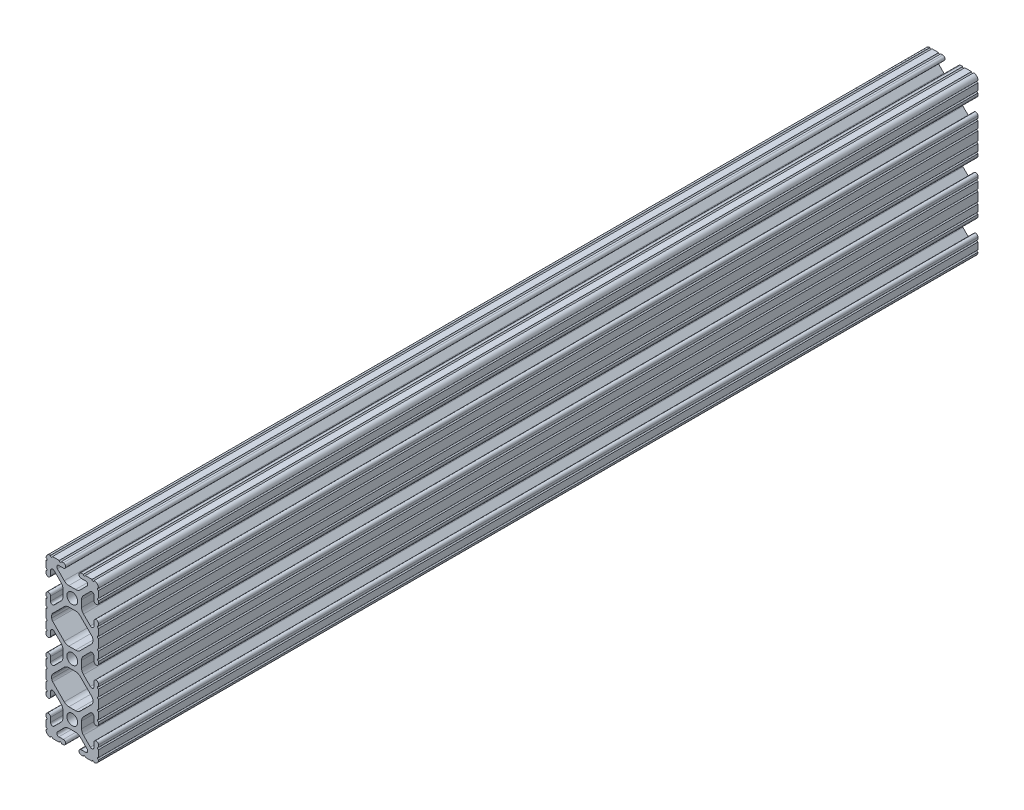
from build123d import *

# Parameters (mm, degrees)
SKETCH1_R           = 2.6035
BOSS_EXTRUDE1_DEPTH = 212.725


with BuildPart() as part:
    # Sketch1 → Boss-Extrude1 (new body, symmetric)
    with BuildSketch(Plane.XY):
        with BuildLine():
            Line((-12.7, 34.9504), (-12.7, 31.7246))
            ThreePointArc((-12.7, 31.7246), (-12.192, 31.2166), (-12.7, 30.7086))
            Line((-12.7, 30.7086), (-12.7, 29.702307889))
            ThreePointArc((-12.7, 29.702307889), (-11.5951, 28.597407889), (-10.4902, 29.702307889))
            Line((-10.4902, 29.702307889), (-10.4902, 31.874794456))
            ThreePointArc((-10.4902, 31.874794456), (-9.863006367, 32.813456061), (-8.75577951, 32.593214945))
            Line((-8.75577951, 32.593214945), (-5.43843597, 29.275871405))
            ThreePointArc((-5.43843597, 29.275871405), (-4.750182484, 28.245827272), (-4.5085, 27.030807374))
            Line((-4.5085, 27.030807374), (-4.5085, 23.769192626))
            ThreePointArc((-4.5085, 23.769192626), (-4.750182484, 22.554172728), (-5.43843597, 21.524128595))
            Line((-5.43843597, 21.524128595), (-8.75577951, 18.206785055))
            ThreePointArc((-8.75577951, 18.206785055), (-9.863006367, 17.986543939), (-10.4902, 18.925205544))
            Line((-10.4902, 18.925205544), (-10.4902, 21.097692111))
            ThreePointArc((-10.4902, 21.097692111), (-11.5951, 22.202592111), (-12.7, 21.097692111))
            Line((-12.7, 21.097692111), (-12.7, 20.0914))
            ThreePointArc((-12.7, 20.0914), (-12.192, 19.5834), (-12.7, 19.0754))
            Line((-12.7, 19.0754), (-12.7, 15.8496))
            ThreePointArc((-12.7, 15.8496), (-12.192, 15.3416), (-12.7, 14.8336))
            Line((-12.7, 14.8336), (-12.7, 10.5664))
            ThreePointArc((-12.7, 10.5664), (-12.192, 10.0584), (-12.7, 9.5504))
            Line((-12.7, 9.5504), (-12.7, 6.3246))
            ThreePointArc((-12.7, 6.3246), (-12.192000017, 5.8166), (-12.7, 5.3086))
            Line((-12.7, 5.3086), (-12.7, 4.302307889))
            ThreePointArc((-12.7, 4.302307889), (-11.5951, 3.197407889), (-10.4902, 4.302307889))
            Line((-10.4902, 4.302307889), (-10.4902, 6.474794456))
            ThreePointArc((-10.4902, 6.474794456), (-9.863006367, 7.413456061), (-8.75577951, 7.193214945))
            Line((-8.75577951, 7.193214945), (-5.43843597, 3.875871405))
            ThreePointArc((-5.43843597, 3.875871405), (-4.750182484, 2.845827272), (-4.5085, 1.630807374))
            Line((-4.5085, 1.630807374), (-4.5085, -1.630807374))
            ThreePointArc((-4.5085, -1.630807374), (-4.750182484, -2.845827272), (-5.43843597, -3.875871405))
            Line((-5.43843597, -3.875871405), (-8.75577951, -7.193214945))
            ThreePointArc((-8.75577951, -7.193214945), (-9.863006367, -7.413456061), (-10.4902, -6.474794456))
            Line((-10.4902, -6.474794456), (-10.4902, -4.302307889))
            ThreePointArc((-10.4902, -4.302307889), (-11.5951, -3.197407889), (-12.7, -4.302307889))
            Line((-12.7, -4.302307889), (-12.7, -5.3086))
            ThreePointArc((-12.7, -5.3086), (-12.191999983, -5.8166), (-12.7, -6.3246))
            Line((-12.7, -6.3246), (-12.7, -9.5504))
            ThreePointArc((-12.7, -9.5504), (-12.192, -10.0584), (-12.7, -10.5664))
            Line((-12.7, -10.5664), (-12.7, -14.8336))
            ThreePointArc((-12.7, -14.8336), (-12.192, -15.3416), (-12.7, -15.8496))
            Line((-12.7, -15.8496), (-12.7, -19.0754))
            ThreePointArc((-12.7, -19.0754), (-12.192, -19.5834), (-12.7, -20.0914))
            Line((-12.7, -20.0914), (-12.7, -21.097692111))
            ThreePointArc((-12.7, -21.097692111), (-11.5951, -22.202592111), (-10.4902, -21.097692111))
            Line((-10.4902, -21.097692111), (-10.4902, -18.925205544))
            ThreePointArc((-10.4902, -18.925205544), (-9.863006367, -17.986543939), (-8.75577951, -18.206785055))
            Line((-8.75577951, -18.206785055), (-5.43843597, -21.524128595))
            ThreePointArc((-5.43843597, -21.524128595), (-4.750182484, -22.554172728), (-4.5085, -23.769192626))
            Line((-4.5085, -23.769192626), (-4.5085, -27.030807374))
            ThreePointArc((-4.5085, -27.030807374), (-4.750182484, -28.245827272), (-5.43843597, -29.275871405))
            Line((-5.43843597, -29.275871405), (-8.75577951, -32.593214945))
            ThreePointArc((-8.75577951, -32.593214945), (-9.863006367, -32.813456061), (-10.4902, -31.874794456))
            Line((-10.4902, -31.874794456), (-10.4902, -29.702307889))
            ThreePointArc((-10.4902, -29.702307889), (-11.5951, -28.597407889), (-12.7, -29.702307889))
            Line((-12.7, -29.702307889), (-12.7, -30.7086))
            ThreePointArc((-12.7, -30.7086), (-12.192, -31.2166), (-12.7, -31.7246))
            Line((-12.7, -31.7246), (-12.7, -34.9504))
            ThreePointArc((-12.7, -34.9504), (-12.192, -35.4584), (-12.7, -35.9664))
            ThreePointArc((-12.7, -35.9664), (-12.082677406, -37.482677406), (-10.5664, -38.1))
            ThreePointArc((-10.5664, -38.1), (-10.0584, -37.592), (-9.5504, -38.1))
            Line((-9.5504, -38.1), (-6.3246, -38.1))
            ThreePointArc((-6.3246, -38.1), (-5.816599996, -37.592000017), (-5.3086, -38.100000008))
            Line((-5.3086, -38.100000008), (-4.302307889, -38.100000008))
            ThreePointArc((-4.302307889, -38.100000008), (-3.197407889, -36.995100008), (-4.302307889, -35.890200008))
            Line((-4.302307889, -35.890200008), (-6.474794456, -35.890200008))
            ThreePointArc((-6.474794456, -35.890200008), (-7.413456061, -35.263006376), (-7.193214945, -34.155779519))
            Line((-7.193214945, -34.155779519), (-3.875871405, -30.838435978))
            ThreePointArc((-3.875871405, -30.838435978), (-2.845827272, -30.150182493), (-1.630807374, -29.908500008))
            Line((-1.630807374, -29.908500008), (1.630807374, -29.908500008))
            ThreePointArc((1.630807374, -29.908500008), (2.845827272, -30.150182493), (3.875871405, -30.838435978))
            Line((3.875871405, -30.838435978), (7.193214945, -34.155779519))
            ThreePointArc((7.193214945, -34.155779519), (7.413456061, -35.263006376), (6.474794456, -35.890200008))
            Line((6.474794456, -35.890200008), (4.302307889, -35.890200008))
            ThreePointArc((4.302307889, -35.890200008), (3.197407889, -36.995100008), (4.302307889, -38.100000008))
            Line((4.302307889, -38.100000008), (5.3086, -38.100000008))
            ThreePointArc((5.3086, -38.100000008), (5.8166, -37.591999992), (6.3246, -38.100000008))
            Line((6.3246, -38.100000008), (9.5504, -38.100000008))
            ThreePointArc((9.5504, -38.100000008), (10.0584, -37.592000008), (10.5664, -38.100000008))
            ThreePointArc((10.5664, -38.100000008), (12.082677406, -37.482677414), (12.7, -35.966400008))
            ThreePointArc((12.7, -35.966400008), (12.192, -35.458400008), (12.7, -34.950400008))
            Line((12.7, -34.950400008), (12.7, -31.724600008))
            ThreePointArc((12.7, -31.724600008), (12.192, -31.216600008), (12.7, -30.708600008))
            Line((12.7, -30.708600008), (12.7, -29.702307926))
            ThreePointArc((12.7, -29.702307926), (11.5951, -28.597407926), (10.4902, -29.702307926))
            Line((10.4902, -29.702307926), (10.4902, -31.874794464))
            ThreePointArc((10.4902, -31.874794464), (9.863006367, -32.813456069), (8.75577951, -32.593214954))
            Line((8.75577951, -32.593214954), (5.43843597, -29.275871413))
            ThreePointArc((5.43843597, -29.275871413), (4.750182484, -28.245827281), (4.5085, -27.030807383))
            Line((4.5085, -27.030807383), (4.5085, -23.769192634))
            ThreePointArc((4.5085, -23.769192634), (4.750182484, -22.554172736), (5.43843597, -21.524128604))
            Line((5.43843597, -21.524128604), (8.75577951, -18.206785063))
            ThreePointArc((8.75577951, -18.206785063), (9.863006367, -17.986543948), (10.4902, -18.925205553))
            Line((10.4902, -18.925205553), (10.4902, -21.097692067))
            ThreePointArc((10.4902, -21.097692067), (11.5951, -22.202592067), (12.7, -21.097692067))
            Line((12.7, -21.097692067), (12.7, -20.091400008))
            ThreePointArc((12.7, -20.091400008), (12.192, -19.583400008), (12.7, -19.075400008))
            Line((12.7, -19.075400008), (12.7, -15.849600008))
            ThreePointArc((12.7, -15.849600008), (12.192, -15.341600008), (12.7, -14.833600008))
            Line((12.7, -14.833600008), (12.7, -10.566400008))
            ThreePointArc((12.7, -10.566400008), (12.192, -10.058400008), (12.7, -9.550400008))
            Line((12.7, -9.550400008), (12.7, -6.324600008))
            ThreePointArc((12.7, -6.324600008), (12.192000017, -5.816600008), (12.7, -5.308600008))
            Line((12.7, -5.308600008), (12.7, -4.302307897))
            ThreePointArc((12.7, -4.302307897), (11.5951, -3.197407897), (10.4902, -4.302307897))
            Line((10.4902, -4.302307897), (10.4902, -6.474794464))
            ThreePointArc((10.4902, -6.474794464), (9.863006367, -7.413456069), (8.75577951, -7.193214954))
            Line((8.75577951, -7.193214954), (5.43843597, -3.875871413))
            ThreePointArc((5.43843597, -3.875871413), (4.750182484, -2.845827281), (4.5085, -1.630807383))
            Line((4.5085, -1.630807383), (4.5085, 1.630807366))
            ThreePointArc((4.5085, 1.630807366), (4.750182484, 2.845827264), (5.43843597, 3.875871396))
            Line((5.43843597, 3.875871396), (8.75577951, 7.193214937))
            ThreePointArc((8.75577951, 7.193214937), (9.863006367, 7.413456052), (10.4902, 6.474794447))
            Line((10.4902, 6.474794447), (10.4902, 4.302307881))
            ThreePointArc((10.4902, 4.302307881), (11.5951, 3.197407881), (12.7, 4.302307881))
            Line((12.7, 4.302307881), (12.7, 5.308599992))
            ThreePointArc((12.7, 5.308599992), (12.191999983, 5.816599992), (12.7, 6.324599992))
            Line((12.7, 6.324599992), (12.7, 9.550399992))
            ThreePointArc((12.7, 9.550399992), (12.192, 10.058399992), (12.7, 10.566399992))
            Line((12.7, 10.566399992), (12.7, 14.833599992))
            ThreePointArc((12.7, 14.833599992), (12.192, 15.341599992), (12.7, 15.849599992))
            Line((12.7, 15.849599992), (12.7, 19.075399992))
            ThreePointArc((12.7, 19.075399992), (12.192, 19.583399992), (12.7, 20.091399992))
            Line((12.7, 20.091399992), (12.7, 21.097692074))
            ThreePointArc((12.7, 21.097692074), (11.5951, 22.202592074), (10.4902, 21.097692074))
            Line((10.4902, 21.097692074), (10.4902, 18.925205536))
            ThreePointArc((10.4902, 18.925205536), (9.863006367, 17.986543931), (8.75577951, 18.206785046))
            Line((8.75577951, 18.206785046), (5.43843597, 21.524128587))
            ThreePointArc((5.43843597, 21.524128587), (4.750182484, 22.554172719), (4.5085, 23.769192617))
            Line((4.5085, 23.769192617), (4.5085, 27.030807366))
            ThreePointArc((4.5085, 27.030807366), (4.750182484, 28.245827264), (5.43843597, 29.275871396))
            Line((5.43843597, 29.275871396), (8.75577951, 32.593214937))
            ThreePointArc((8.75577951, 32.593214937), (9.863006367, 32.813456052), (10.4902, 31.874794447))
            Line((10.4902, 31.874794447), (10.4902, 29.702307881))
            ThreePointArc((10.4902, 29.702307881), (11.5951, 28.597407881), (12.7, 29.702307881))
            Line((12.7, 29.702307881), (12.7, 30.708599992))
            ThreePointArc((12.7, 30.708599992), (12.192, 31.216599992), (12.7, 31.724599992))
            Line((12.7, 31.724599992), (12.7, 34.9504))
            ThreePointArc((12.7, 34.9504), (12.192, 35.4584), (12.7, 35.9664))
            ThreePointArc((12.7, 35.9664), (12.082677406, 37.482677406), (10.5664, 38.1))
            ThreePointArc((10.5664, 38.1), (10.0584, 37.592), (9.5504, 38.1))
            Line((9.5504, 38.1), (6.3246, 38.1))
            ThreePointArc((6.3246, 38.1), (5.8166, 37.591999983), (5.3086, 38.1))
            Line((5.3086, 38.1), (4.302307889, 38.1))
            ThreePointArc((4.302307889, 38.1), (3.197407889, 36.9951), (4.302307889, 35.8902))
            Line((4.302307889, 35.8902), (6.474794456, 35.8902))
            ThreePointArc((6.474794456, 35.8902), (7.413456061, 35.263006367), (7.193214945, 34.15577951))
            Line((7.193214945, 34.15577951), (3.875871405, 30.83843597))
            ThreePointArc((3.875871405, 30.83843597), (2.845827272, 30.150182484), (1.630807374, 29.9085))
            Line((1.630807374, 29.9085), (-1.630807374, 29.9085))
            ThreePointArc((-1.630807374, 29.9085), (-2.845827272, 30.150182484), (-3.875871405, 30.83843597))
            Line((-3.875871405, 30.83843597), (-7.193214945, 34.15577951))
            ThreePointArc((-7.193214945, 34.15577951), (-7.413456061, 35.263006367), (-6.474794456, 35.8902))
            Line((-6.474794456, 35.8902), (-4.302307889, 35.8902))
            ThreePointArc((-4.302307889, 35.8902), (-3.197407889, 36.9951), (-4.302307889, 38.1))
            Line((-4.302307889, 38.1), (-5.3086, 38.1))
            ThreePointArc((-5.3086, 38.1), (-5.8166, 37.592000017), (-6.3246, 38.1))
            Line((-6.3246, 38.1), (-9.5504, 38.1))
            ThreePointArc((-9.5504, 38.1), (-10.0584, 37.592), (-10.5664, 38.1))
            ThreePointArc((-10.5664, 38.1), (-12.082677406, 37.482677406), (-12.7, 35.9664))
            ThreePointArc((-12.7, 35.9664), (-12.192, 35.4584), (-12.7, 34.9504))
        make_face()
        with Locations((0, -25.4)):
            Circle(SKETCH1_R, mode=Mode.SUBTRACT)
        Circle(SKETCH1_R, mode=Mode.SUBTRACT)
        with Locations((0, 25.4)):
            Circle(SKETCH1_R, mode=Mode.SUBTRACT)
        with BuildLine():
            Line((-9.9314, -12.146268083), (-9.9314, -13.253731917))
            ThreePointArc((-9.9314, -13.253731917), (-9.811525488, -13.856381786), (-9.470151759, -14.367283676))
            Line((-9.470151759, -14.367283676), (-3.875871405, -19.96156403))
            ThreePointArc((-3.875871405, -19.96156403), (-2.845827272, -20.649817516), (-1.630807374, -20.8915))
            Line((-1.630807374, -20.8915), (1.630807374, -20.8915))
            ThreePointArc((1.630807374, -20.8915), (2.845827272, -20.649817516), (3.875871405, -19.96156403))
            Line((3.875871405, -19.96156403), (9.470151759, -14.367283676))
            ThreePointArc((9.470151759, -14.367283676), (9.811525488, -13.856381786), (9.9314, -13.253731917))
            Line((9.9314, -13.253731917), (9.9314, -12.146268083))
            ThreePointArc((9.9314, -12.146268083), (9.811525488, -11.543618214), (9.470151759, -11.032716324))
            Line((9.470151759, -11.032716324), (3.875871405, -5.43843597))
            ThreePointArc((3.875871405, -5.43843597), (2.845827272, -4.750182484), (1.630807374, -4.5085))
            Line((1.630807374, -4.5085), (-1.630807374, -4.5085))
            ThreePointArc((-1.630807374, -4.5085), (-2.845827272, -4.750182484), (-3.875871405, -5.43843597))
            Line((-3.875871405, -5.43843597), (-9.470151759, -11.032716324))
            ThreePointArc((-9.470151759, -11.032716324), (-9.811525488, -11.543618214), (-9.9314, -12.146268083))
        make_face(mode=Mode.SUBTRACT)
        with BuildLine():
            Line((-9.9314, 13.253731917), (-9.9314, 12.146268083))
            ThreePointArc((-9.9314, 12.146268083), (-9.811525488, 11.543618214), (-9.470151759, 11.032716324))
            Line((-9.470151759, 11.032716324), (-3.875871405, 5.43843597))
            ThreePointArc((-3.875871405, 5.43843597), (-2.845827272, 4.750182484), (-1.630807374, 4.5085))
            Line((-1.630807374, 4.5085), (1.630807374, 4.5085))
            ThreePointArc((1.630807374, 4.5085), (2.845827272, 4.750182484), (3.875871405, 5.43843597))
            Line((3.875871405, 5.43843597), (9.470151759, 11.032716324))
            ThreePointArc((9.470151759, 11.032716324), (9.811525488, 11.543618214), (9.9314, 12.146268083))
            Line((9.9314, 12.146268083), (9.9314, 13.253731917))
            ThreePointArc((9.9314, 13.253731917), (9.811525488, 13.856381786), (9.470151759, 14.367283676))
            Line((9.470151759, 14.367283676), (3.875871405, 19.96156403))
            ThreePointArc((3.875871405, 19.96156403), (2.845827272, 20.649817516), (1.630807374, 20.8915))
            Line((1.630807374, 20.8915), (-1.630807374, 20.8915))
            ThreePointArc((-1.630807374, 20.8915), (-2.845827272, 20.649817516), (-3.875871405, 19.96156403))
            Line((-3.875871405, 19.96156403), (-9.470151759, 14.367283676))
            ThreePointArc((-9.470151759, 14.367283676), (-9.811525488, 13.856381786), (-9.9314, 13.253731917))
        make_face(mode=Mode.SUBTRACT)
    extrude(amount=BOSS_EXTRUDE1_DEPTH, both=True)


solid = part.part
